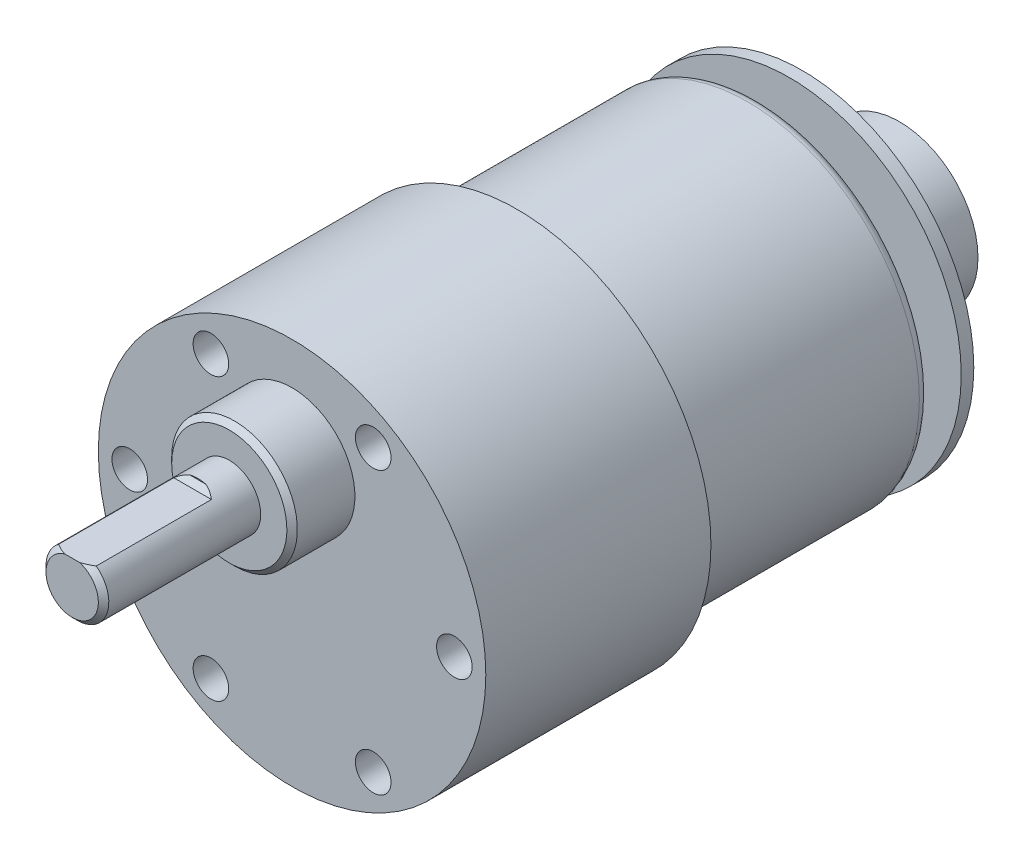
from build123d import *

# Parameters (mm, degrees)
ESQUISSE3_W                  = 5.995341806
ESQUISSE3_H                  = 6
ESQUISSE4_W                  = 15.004658194
ESQUISSE4_H                  = 3
ESQUISSE5_W                  = 5
ESQUISSE5_H                  = 1
ENL_V_MAT_EXTRU_1_DEPTH      = 12
CHANFREIN1_SIZE              = 0.5
ESQUISSE6_W                  = 3
ESQUISSE6_H                  = 3
ESQUISSE7_W                  = 1.2
ESQUISSE7_H                  = 16.4
ESQUISSE8_W                  = 9.3
ESQUISSE8_H                  = 7.5
R_P_TITION_CIRCULAIRE1_COUNT = 6
CONG_1_R                     = 1
CHANFREIN2_SIZE              = 0.5


with BuildPart() as part:
    # Esquisse1 → Révolution1 (revolve)
    with BuildSketch(Plane(origin=(0, 0, 0), x_dir=(0, 0, -1), z_dir=(1, 0, 0))):
        Polygon((0, 0), (0, 16.4), (-23, 16.4), (-23, 18.5), (-44.5, 18.5), (-44.5, 0), align=None)
    revolve(axis=Axis((0, 0, 44.5), (0, 0, -1)))

    # Esquisse3 → Révolution2 (revolve)
    with BuildSketch(Plane(origin=(0, 0, 0), x_dir=(0, 0, -1), z_dir=(1, 0, 0))):
        with Locations((-47.497670903, 11.5)):
            Rectangle(ESQUISSE3_W, ESQUISSE3_H)
    revolve(axis=Axis((0, 8.5, 50.495341806), (0, 0, -1)))

    # Esquisse4 → Révolution3 (revolve)
    with BuildSketch(Plane(origin=(0, 0, 0), x_dir=(0, 0, -1), z_dir=(1, 0, 0))):
        with Locations((-57.997670903, 10)):
            Rectangle(ESQUISSE4_W, ESQUISSE4_H)
    revolve(axis=Axis((0, 8.5, 50.495341806), (0, 0, 1)))

    # Esquisse5 → Enlèv. mat.-Extru.1 (cut)
    with BuildSketch(Plane.XY.offset(65.5)):
        with Locations((0, 11.4)):
            Rectangle(ESQUISSE5_W, ESQUISSE5_H)
    extrude(amount=-ENL_V_MAT_EXTRU_1_DEPTH, mode=Mode.SUBTRACT)

    # Chanfrein1
    chanfrein1_edges = [part.edges().sort_by_distance(p)[0] for p in [
        (0, 5.5, 65.5),
        (0, 10.9, 53.5),
    ]]
    chamfer(chanfrein1_edges, length=CHANFREIN1_SIZE)

    # Esquisse6 → Révolution4 (revolve)
    with BuildSketch(Plane(origin=(0, 0, 0), x_dir=(0, 0, -1), z_dir=(1, 0, 0))):
        with Locations((1.5, 1.5)):
            Rectangle(ESQUISSE6_W, ESQUISSE6_H)
    revolve(axis=Axis((0, 0, 0), (0, 0, -1)))

    # Esquisse7 → Révolution5 (revolve)
    with BuildSketch(Plane(origin=(0, 0, 0), x_dir=(0, 0, -1), z_dir=(1, 0, 0))):
        with Locations((3.6, 8.2)):
            Rectangle(ESQUISSE7_W, ESQUISSE7_H)
    revolve(axis=Axis((0, 0, -3), (0, 0, -1)))

    # Esquisse8 → Révolution6 (revolve)
    with BuildSketch(Plane(origin=(0, 0, 0), x_dir=(0, 0, -1), z_dir=(1, 0, 0))):
        with Locations((8.85, 3.75)):
            Rectangle(ESQUISSE8_W, ESQUISSE8_H)
    revolve(axis=Axis((0, 0, -4.2), (0, 0, -1)))

    # Esquisse12 → Dégagement M31 (revolve, cut)
    with BuildSketch(Plane(origin=(15.5, 0, 44.5), x_dir=(0, -1, 0), z_dir=(1, 0, 0))):
        Polygon((0, 0), (0, 11.021463052), (1.7, 10), (1.7, 0), align=None)
    d_gagement_m31 = revolve(axis=Axis((15.5, 0, 50.85), (0, 0, -1)), mode=Mode.SUBTRACT)

    # Répétition circulaire1: Dégagement M31 ×6 about axis
    r_p_tition_circulaire1_axis = Axis((0, 0, 0), (0, 0, 1))
    for i in range(1, R_P_TITION_CIRCULAIRE1_COUNT):
        add(d_gagement_m31.rotate(r_p_tition_circulaire1_axis, i * 360 / R_P_TITION_CIRCULAIRE1_COUNT), mode=Mode.SUBTRACT)

    # Congé1
    cong_1_edges = [part.edges().sort_by_distance(p)[0] for p in [
        (0, -16.4, 0),
    ]]
    fillet(cong_1_edges, radius=CONG_1_R)

    # Chanfrein2
    chanfrein2_edges = [part.edges().sort_by_distance(p)[0] for p in [
        (0, 2.5, 50.495341806),
    ]]
    chamfer(chanfrein2_edges, length=CHANFREIN2_SIZE)


solid = part.part
